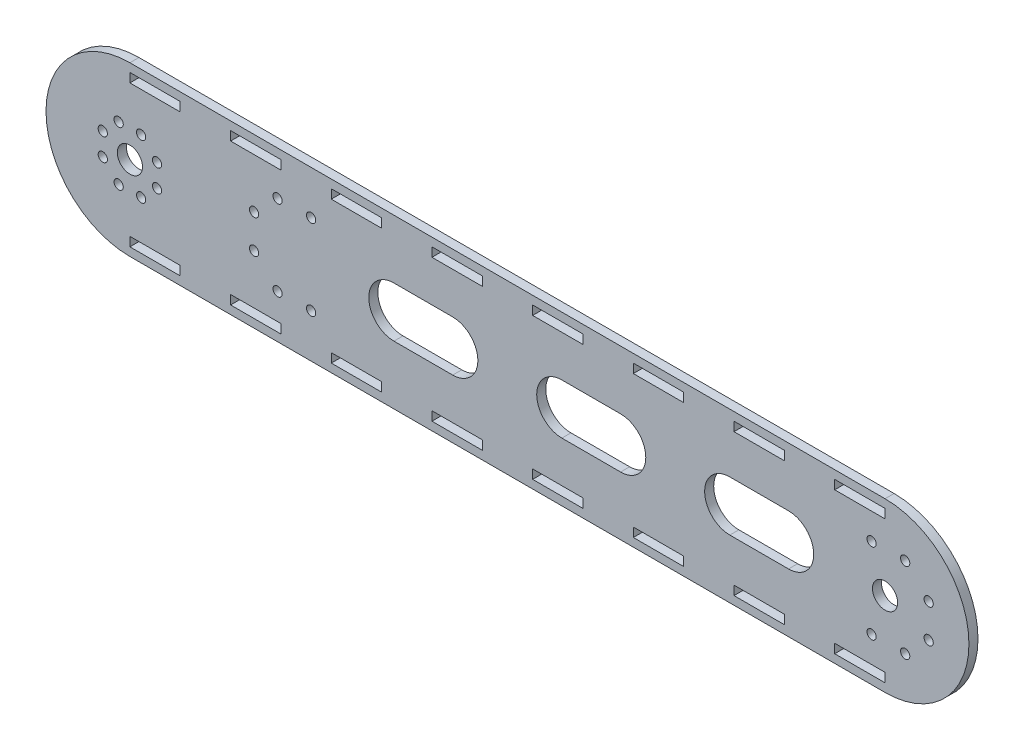
from build123d import *

# Parameters (mm, degrees)
SKETCH3_R           = 7.5
SKETCH3_R_2         = 2.75
SKETCH3_W           = 30
SKETCH3_H           = 5.4
BOSS_EXTRUDE1_DEPTH = 5.4


with BuildPart() as part:
    # Sketch3 → Boss-Extrude1 (new body)
    with BuildSketch(Plane.XY):
        with BuildLine():
            Line((-242.5, 50), (207.5, 50))
            ThreePointArc((207.5, 50), (257.5, 0), (207.5, -50))
            Line((207.5, -50), (-242.5, -50))
            ThreePointArc((-242.5, -50), (-292.5, 0), (-242.5, 50))
        make_face()
        with Locations((-242.5, 0)):
            Circle(SKETCH3_R, mode=Mode.SUBTRACT)
        with Locations((207.5, 0)):
            Circle(SKETCH3_R, mode=Mode.SUBTRACT)
        with Locations((-226.332108181, 6.696960066)):
            Circle(SKETCH3_R_2, mode=Mode.SUBTRACT)
        with Locations((-226.332108181, -6.696960066)):
            Circle(SKETCH3_R_2, mode=Mode.SUBTRACT)
        with Locations((-235.803039934, -16.167891819)):
            Circle(SKETCH3_R_2, mode=Mode.SUBTRACT)
        with Locations((-249.196960066, -16.167891819)):
            Circle(SKETCH3_R_2, mode=Mode.SUBTRACT)
        with Locations((-258.667891819, -6.696960066)):
            Circle(SKETCH3_R_2, mode=Mode.SUBTRACT)
        with Locations((-258.667891819, 6.696960066)):
            Circle(SKETCH3_R_2, mode=Mode.SUBTRACT)
        with Locations((-249.196960066, 16.167891819)):
            Circle(SKETCH3_R_2, mode=Mode.SUBTRACT)
        with Locations((-235.803039934, 16.167891819)):
            Circle(SKETCH3_R_2, mode=Mode.SUBTRACT)
        with Locations((-134.5, -24)):
            Circle(SKETCH3_R_2, mode=Mode.SUBTRACT)
        with Locations((-154.5, -24)):
            Circle(SKETCH3_R_2, mode=Mode.SUBTRACT)
        with Locations((-168.5, -10)):
            Circle(SKETCH3_R_2, mode=Mode.SUBTRACT)
        with Locations((-168.5, 10)):
            Circle(SKETCH3_R_2, mode=Mode.SUBTRACT)
        with Locations((-154.5, 24)):
            Circle(SKETCH3_R_2, mode=Mode.SUBTRACT)
        with Locations((-134.5, 24)):
            Circle(SKETCH3_R_2, mode=Mode.SUBTRACT)
        with Locations((199.5, -24)):
            Circle(SKETCH3_R_2, mode=Mode.SUBTRACT)
        with Locations((219.5, -24)):
            Circle(SKETCH3_R_2, mode=Mode.SUBTRACT)
        with Locations((233.5, -10)):
            Circle(SKETCH3_R_2, mode=Mode.SUBTRACT)
        with Locations((233.5, 10)):
            Circle(SKETCH3_R_2, mode=Mode.SUBTRACT)
        with Locations((219.5, 24)):
            Circle(SKETCH3_R_2, mode=Mode.SUBTRACT)
        with Locations((199.5, 24)):
            Circle(SKETCH3_R_2, mode=Mode.SUBTRACT)
        with BuildLine():
            Line((115, 15), (150, 15))
            ThreePointArc((150, 15), (165, 0), (150, -15))
            Line((150, -15), (115, -15))
            ThreePointArc((115, -15), (100, 0), (115, 15))
        make_face(mode=Mode.SUBTRACT)
        with Locations((-227.5, 42.3)):
            Rectangle(SKETCH3_W, SKETCH3_H, mode=Mode.SUBTRACT)
        with Locations((-167.5, 42.3)):
            Rectangle(SKETCH3_W, SKETCH3_H, mode=Mode.SUBTRACT)
        with BuildLine():
            Line((14.924, 15), (49.924, 15))
            ThreePointArc((49.924, 15), (64.924, 0), (49.924, -15))
            Line((49.924, -15), (14.924, -15))
            ThreePointArc((14.924, -15), (-0.076, 0), (14.924, 15))
        make_face(mode=Mode.SUBTRACT)
        with BuildLine():
            Line((-85.152, 15), (-50.152, 15))
            ThreePointArc((-50.152, 15), (-35.152, 0), (-50.152, -15))
            Line((-50.152, -15), (-85.152, -15))
            ThreePointArc((-85.152, -15), (-100.152, 0), (-85.152, 15))
        make_face(mode=Mode.SUBTRACT)
        with Locations((-107.5, 42.3)):
            Rectangle(SKETCH3_W, SKETCH3_H, mode=Mode.SUBTRACT)
        with Locations((-47.5, 42.3)):
            Rectangle(SKETCH3_W, SKETCH3_H, mode=Mode.SUBTRACT)
        with Locations((12.5, 42.3)):
            Rectangle(SKETCH3_W, SKETCH3_H, mode=Mode.SUBTRACT)
        with Locations((72.5, 42.3)):
            Rectangle(SKETCH3_W, SKETCH3_H, mode=Mode.SUBTRACT)
        with Locations((132.5, 42.3)):
            Rectangle(SKETCH3_W, SKETCH3_H, mode=Mode.SUBTRACT)
        with Locations((192.5, 42.3)):
            Rectangle(SKETCH3_W, SKETCH3_H, mode=Mode.SUBTRACT)
        with Locations((192.5, -42.3)):
            Rectangle(SKETCH3_W, SKETCH3_H, mode=Mode.SUBTRACT)
        with Locations((132.5, -42.3)):
            Rectangle(SKETCH3_W, SKETCH3_H, mode=Mode.SUBTRACT)
        with Locations((72.5, -42.3)):
            Rectangle(SKETCH3_W, SKETCH3_H, mode=Mode.SUBTRACT)
        with Locations((12.5, -42.3)):
            Rectangle(SKETCH3_W, SKETCH3_H, mode=Mode.SUBTRACT)
        with Locations((-47.5, -42.3)):
            Rectangle(SKETCH3_W, SKETCH3_H, mode=Mode.SUBTRACT)
        with Locations((-107.5, -42.3)):
            Rectangle(SKETCH3_W, SKETCH3_H, mode=Mode.SUBTRACT)
        with Locations((-167.5, -42.3)):
            Rectangle(SKETCH3_W, SKETCH3_H, mode=Mode.SUBTRACT)
        with Locations((-227.5, -42.3)):
            Rectangle(SKETCH3_W, SKETCH3_H, mode=Mode.SUBTRACT)
    extrude(amount=BOSS_EXTRUDE1_DEPTH)


solid = part.part
